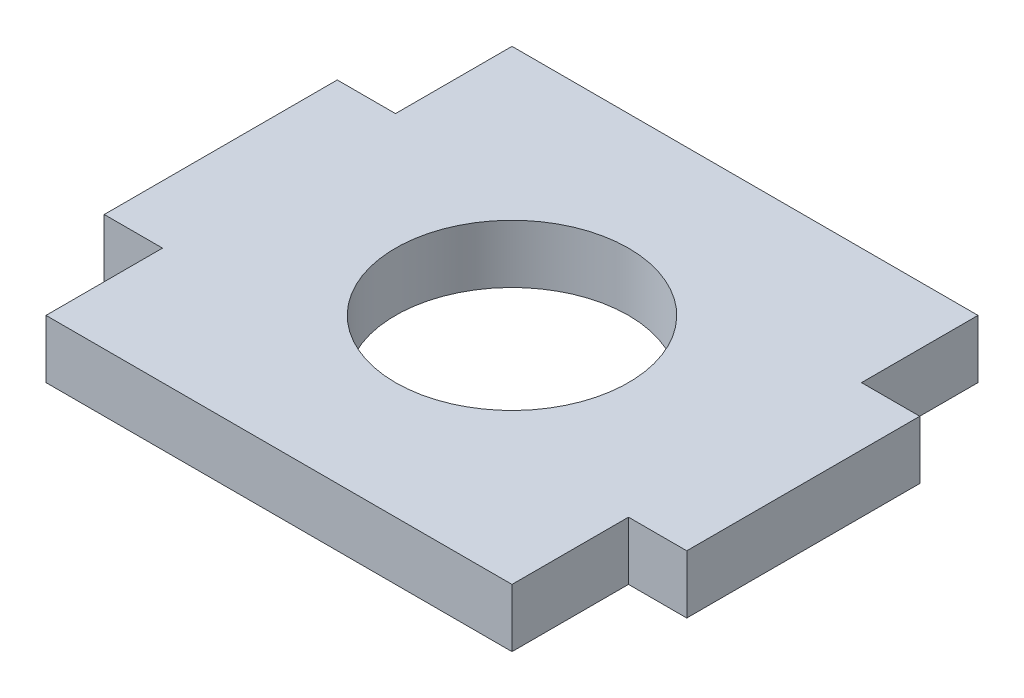
from build123d import *

# Parameters (mm, degrees)
BOSS_EXTRUDE1_DEPTH = 3.175
SKETCH2_R           = 6.35
CUT_EXTRUDE1_DEPTH  = 4.175


with BuildPart() as part:
    # Sketch1 → Boss-Extrude1 (new body)
    with BuildSketch(Plane(origin=(0, 0, 0), x_dir=(1, 0, 0), z_dir=(0, 1, 0))):
        Polygon((-12.7, 6.35), (-12.7, 12.7), (12.7, 12.7), (12.7, 6.35), (15.875, 6.35), (15.875, -6.35), (12.7, -6.35), (12.7, -12.7), (-12.7, -12.7), (-12.7, -6.35), (-15.875, -6.35), (-15.875, 6.35), align=None)
    extrude(amount=BOSS_EXTRUDE1_DEPTH)

    # Sketch2 → Cut-Extrude1 (cut, through all)
    with BuildSketch(Plane(origin=(0, 3.175, 0), x_dir=(1, 0, 0), z_dir=(0, 1, 0))):
        Circle(SKETCH2_R)
    extrude(amount=-CUT_EXTRUDE1_DEPTH, mode=Mode.SUBTRACT)


solid = part.part
